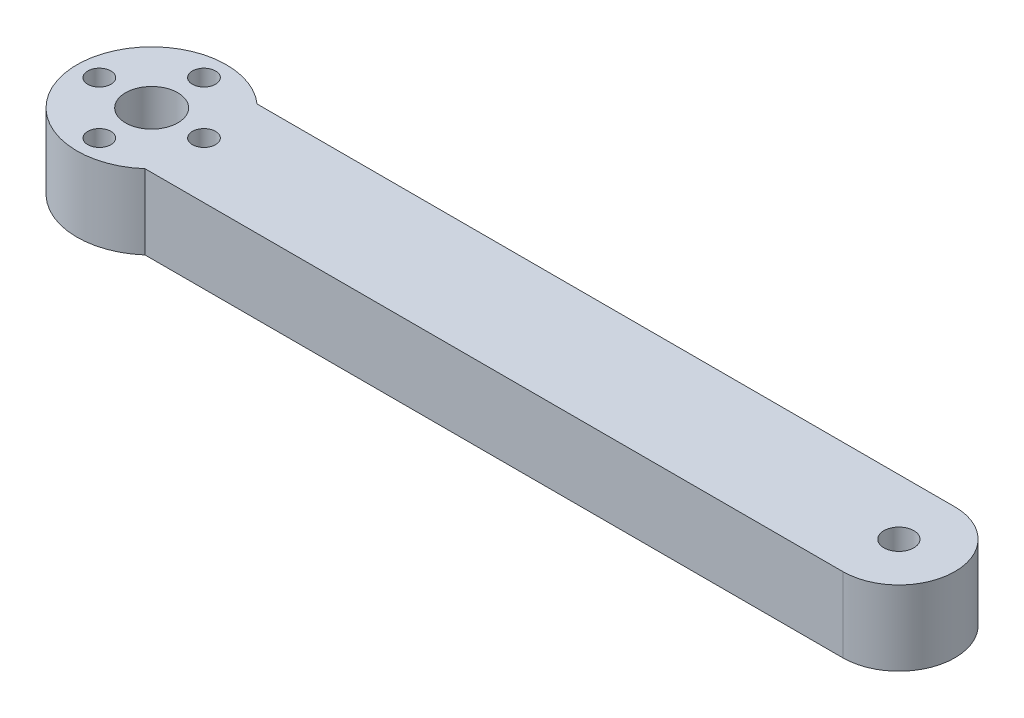
from build123d import *

# Parameters (mm, degrees)
SKETCH2_R           = 2.5
SKETCH2_R_2         = 2
BOSS_EXTRUDE1_DEPTH = 10
SKETCH4_R           = 1.5
CUT_EXTRUDE3_DEPTH  = 110.001146783
SKETCH7_R           = 10
BOSS_EXTRUDE4_DEPTH = 10
SKETCH8_R           = 1.55
SKETCH8_R_2         = 3.5
CUT_EXTRUDE7_DEPTH  = 10


with BuildPart() as part:
    # Sketch2 → Boss-Extrude1 (new body)
    with BuildSketch(Plane(origin=(0, 0, 0), x_dir=(1, 0, 0), z_dir=(0, 1, 0))):
        with BuildLine():
            Line((0, 7.5), (100, 7.5))
            ThreePointArc((100, 7.5), (107.5, 0), (100, -7.5))
            Line((100, -7.5), (0, -7.5))
            ThreePointArc((0, -7.5), (-7.5, 0), (0, 7.5))
        make_face()
        Circle(SKETCH2_R, mode=Mode.SUBTRACT)
        with Locations((100, 0)):
            Circle(SKETCH2_R_2, mode=Mode.SUBTRACT)
    extrude(amount=BOSS_EXTRUDE1_DEPTH)

    # Sketch4 → Cut-Extrude3 (cut, through all)
    with BuildSketch(Plane(origin=(0, 0, -7.5), x_dir=(-1, 0, 0), z_dir=(0, 0, -1))):
        with Locations((0, 5)):
            Circle(SKETCH4_R)
    extrude(amount=-CUT_EXTRUDE3_DEPTH, mode=Mode.SUBTRACT)

    # Sketch7 → Boss-Extrude4 (add)
    with BuildSketch(Plane(origin=(0, 10, 0), x_dir=(1, 0, 0), z_dir=(0, 1, 0))):
        Circle(SKETCH7_R)
    extrude(amount=-BOSS_EXTRUDE4_DEPTH)

    # Sketch8 → Cut-Extrude7 (cut)
    with BuildSketch(Plane(origin=(0, 10, 0), x_dir=(1, 0, 0), z_dir=(0, 1, 0))):
        with Locations((0, 7)):
            Circle(SKETCH8_R)
        with Locations((7, 0)):
            Circle(SKETCH8_R)
        with Locations((0, -7)):
            Circle(SKETCH8_R)
        with Locations((-7, 0)):
            Circle(SKETCH8_R)
        Circle(SKETCH8_R_2)
    extrude(amount=-CUT_EXTRUDE7_DEPTH, mode=Mode.SUBTRACT)


solid = part.part
